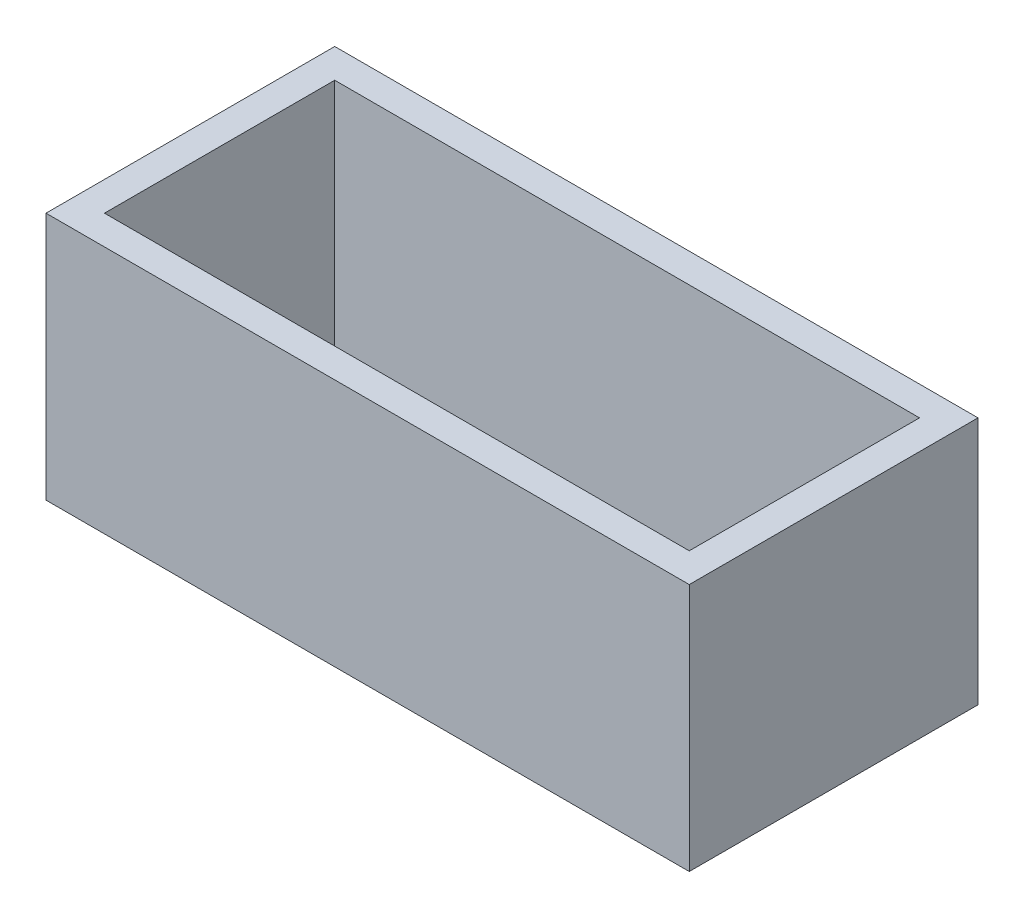
from build123d import *

# Parameters (mm, degrees)
SKETCH1_W           = 44
SKETCH1_H           = 19.75
SKETCH1_W_2         = 40
SKETCH1_H_2         = 15.75
BOSS_EXTRUDE1_DEPTH = 17


with BuildPart() as part:
    # Sketch1 → Boss-Extrude1 (new body)
    with BuildSketch(Plane(origin=(0, 0, 0), x_dir=(1, 0, 0), z_dir=(0, 1, 0))):
        Rectangle(SKETCH1_W, SKETCH1_H)
        Rectangle(SKETCH1_W_2, SKETCH1_H_2, mode=Mode.SUBTRACT)
    extrude(amount=BOSS_EXTRUDE1_DEPTH)


solid = part.part
